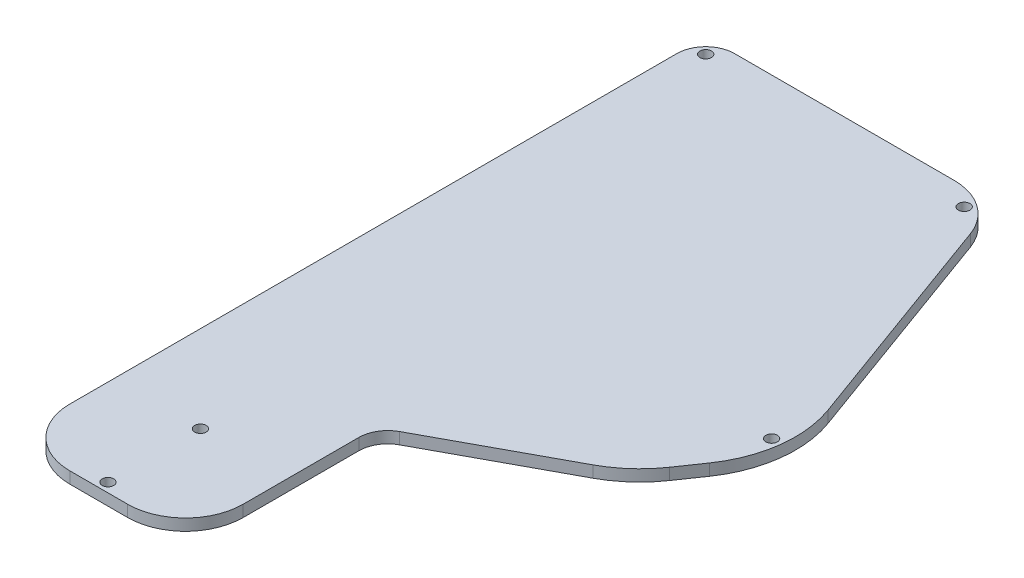
from build123d import *

# Parameters (mm, degrees)
OHGC_BASE_DEPTH  = 2.54
SKETCH7_R        = 1.27
SCREWHOLES_DEPTH = 3.54


with BuildPart() as part:
    # Sketch2 → OHGC BASE (new body)
    with BuildSketch(Plane(origin=(0, 0, 0), x_dir=(1, 0, 0), z_dir=(0, 1, 0))):
        with BuildLine():
            Line((12.7, 0), (25.4, 0))
            ThreePointArc((25.4, 0), (34.380256121, 3.719743879), (38.1, 12.7))
            Line((38.1, 12.7), (38.1, 38.1))
            ThreePointArc((38.1, 38.1), (38.996434372, 41.352863652), (41.432636832, 43.68730879))
            Line((41.432636832, 43.68730879), (69.022459682, 58.586881809))
            ThreePointArc((69.022459682, 58.586881809), (73.920701901, 62.034864891), (77.875264971, 66.534064274))
            Line((77.875264971, 66.534064274), (81.475778144, 71.764628765))
            ThreePointArc((81.475778144, 71.764628765), (85.749269843, 82.951996559), (84.42171275, 94.853993098))
            Line((84.42171275, 94.853993098), (66.518139685, 144.04365582))
            ThreePointArc((66.518139685, 144.04365582), (61.868464143, 150.103230962), (54.584043401, 152.4))
            Line((54.584043401, 152.4), (6.35, 152.4))
            ThreePointArc((6.35, 152.4), (1.859871939, 150.540128061), (0, 146.05))
            Line((0, 146.05), (0, 12.7))
            ThreePointArc((0, 12.7), (3.719743879, 3.719743879), (12.7, 0))
        make_face()
    extrude(amount=OHGC_BASE_DEPTH)

    # Sketch7 → Screwholes (cut, through all)
    with BuildSketch(Plane(origin=(0, 0, 0), x_dir=(1, 0, 0), z_dir=(0, 1, 0))):
        with Locations((3.302, 149.098)):
            Circle(SKETCH7_R)
        with Locations((60.719962059, 148.463)):
            Circle(SKETCH7_R)
        with Locations((83.655901234, 83.21908607)):
            Circle(SKETCH7_R)
        with Locations((19.05, 22.352)):
            Circle(SKETCH7_R)
        with Locations((19.05, 2.032)):
            Circle(SKETCH7_R)
    extrude(amount=SCREWHOLES_DEPTH, mode=Mode.SUBTRACT)


solid = part.part
